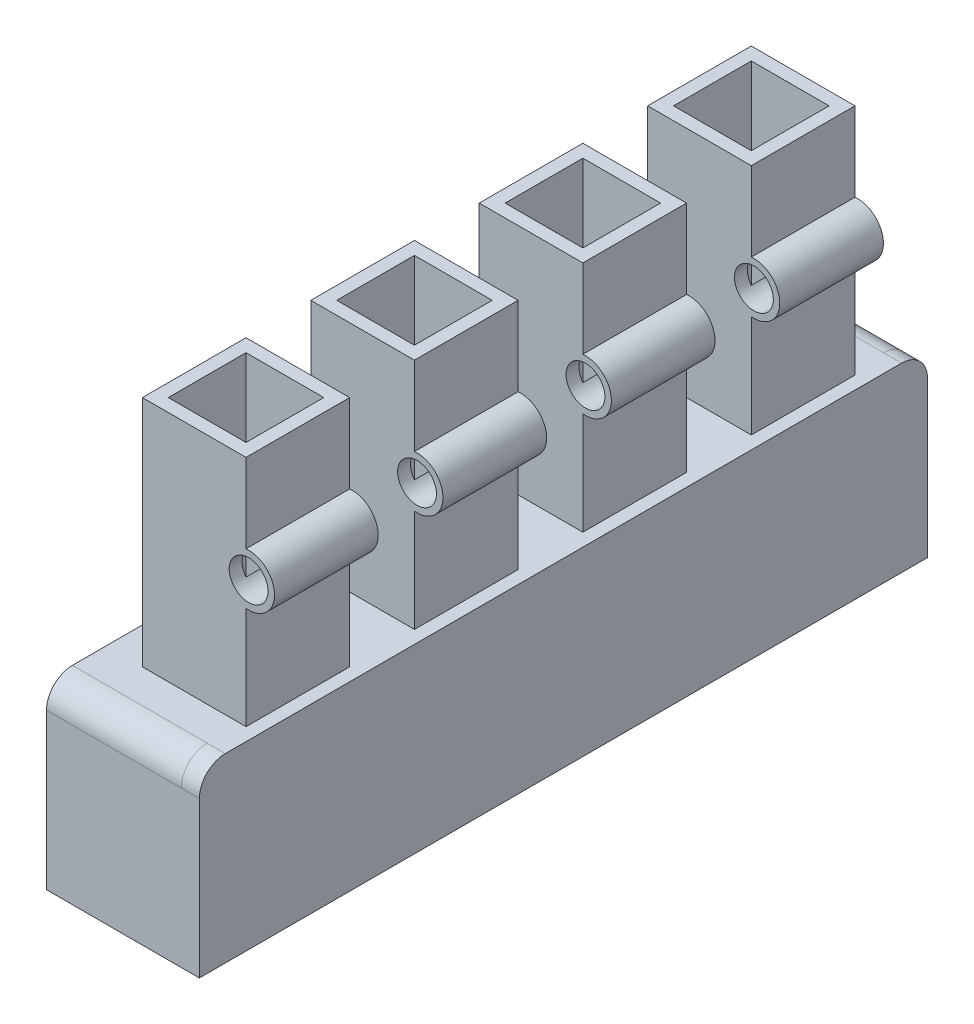
from build123d import *
from build123d.topology import SkipClean

# Parameters (mm, degrees)
BOSS_EXTRUDE1_DEPTH     = 50
BOSS_EXTRUDE2_START     = 9
BOSS_EXTRUDE2_DEPTH     = 9
BOSS_EXTRUDE3_START     = 9
BOSS_EXTRUDE3_DEPTH     = 9
BOSS_EXTRUDE4_DEPTH     = 70
CUT_EXTRUDE2_DEPTH      = 165.74298164110058
CUT_EXTRUDE2_DEPTH_BACK = 165.74298164110058
SKETCH10_W              = 30.000000000000007
SKETCH10_H              = 30
SKETCH10_W_2            = 30.00000000000001
SKETCH10_H_2            = 29.999999999999996
BOSS_EXTRUDE7_DEPTH     = 90
BOSS_EXTRUDE8_DEPTH     = 235
SKETCH12_W              = 24.999999999999993
SKETCH12_H              = 40.90326072663956
SKETCH12_H_2            = 38.73852460954424
SKETCH12_W_2            = 25.000000000000007
SKETCH12_H_3            = 39.91957718910348
CUT_EXTRUDE3_DEPTH      = 235
SKETCH13_R              = 7.499999999999999
CUT_EXTRUDE4_DEPTH      = 235
FILLET1_R               = 10


with BuildPart() as part:
    # Sketch1 → Boss-Extrude1 (new body)
    with BuildSketch(Plane(origin=(0, 0, 0), x_dir=(0, 0, -1), z_dir=(1, 0, 0))):
        with BuildLine():
            Line((-130.5, 0), (130.5, 0))
            ThreePointArc((130.5, 0), (137.57106781186548, -2.9289321881345245), (140.5, -9.999999999999998))
            Line((140.5, -9.999999999999998), (140.5, -69.99999999999999))
            Line((140.5, -69.99999999999999), (122.5, -70))
            ThreePointArc((122.5, -70), (97.5, -45), (72.50000000000001, -70))
            Line((72.50000000000001, -70), (57.5, -70))
            ThreePointArc((57.5, -70), (32.5, -45), (7.5, -70))
            Line((7.5, -70), (-7.5, -70))
            ThreePointArc((-7.5, -70), (-32.5, -45), (-57.5, -70))
            Line((-57.5, -70), (-72.50000000000001, -70))
            ThreePointArc((-72.50000000000001, -70), (-97.5, -45), (-122.5, -70))
            Line((-122.5, -70), (-140.5, -69.99999999999999))
            Line((-140.5, -69.99999999999999), (-140.5, -9.999999999999998))
            ThreePointArc((-140.5, -9.999999999999998), (-137.57106781186548, -2.9289321881345245), (-130.5, 0))
        make_face()
    extrude(amount=BOSS_EXTRUDE1_DEPTH)

    # Sketch2 → Boss-Extrude2 (add)
    with BuildSketch(Plane.ZY.offset(BOSS_EXTRUDE2_START)):
        with BuildLine():
            Line((0, 0), (130.5, 0))
            ThreePointArc((130.5, 0), (137.57106781186548, -2.9289321881345236), (140.5, -9.999999999999998))
            Line((140.5, -9.999999999999998), (140.5, -69.99999999999999))
            Line((140.5, -69.99999999999999), (135.5, -69.99999999999999))
            Line((135.5, -69.99999999999999), (135.5, -15))
            ThreePointArc((135.5, -15), (132.57106781186548, -7.928932188134525), (125.5, -5.000000000000002))
            Line((125.5, -5.000000000000002), (0, -5.000000000000017))
            Line((0, -5.000000000000017), (0, 0))
        make_face()
    extrude(amount=-BOSS_EXTRUDE2_DEPTH)

    # Sketch3 → Boss-Extrude3 (add)
    with BuildSketch(Plane.ZY.offset(BOSS_EXTRUDE3_START)):
        with BuildLine():
            Line((0, 0), (0, -5.000000000000017))
            Line((0, -5.000000000000017), (-125.5, -5.000000000000032))
            ThreePointArc((-125.5, -5.000000000000032), (-132.57106781186548, -7.9289321881345565), (-135.5, -15.000000000000034))
            Line((-135.5, -15.000000000000034), (-135.5, -69.99999999999999))
            Line((-135.5, -69.99999999999999), (-140.5, -69.99999999999999))
            Line((-140.5, -69.99999999999999), (-140.5, -10.00000000000007))
            ThreePointArc((-140.5, -10.00000000000007), (-137.5710678118655, -2.9289321881345742), (-130.50000000000003, 5.2e-15))
            Line((-130.50000000000003, 5.2e-15), (0, 0))
        make_face()
    extrude(amount=-BOSS_EXTRUDE3_DEPTH)

    # Sketch6 → Boss-Extrude4 (add)
    with BuildSketch(Plane(origin=(0, 0, 0), x_dir=(1, 0, 0), z_dir=(0, 1, 0))):
        Polygon((50, -140.5), (50, 140.5), (43, 140.5), (43.000000000000036, -140.5), align=None)
    extrude(amount=-BOSS_EXTRUDE4_DEPTH)

    # Sketch9 → Cut-Extrude2 (cut, two sides: drawn at the far end of the back side and taken through both)
    with BuildSketch(Plane(origin=(0, 0, 0), x_dir=(1, 0, 0), z_dir=(0, 1, 0)).offset(-CUT_EXTRUDE2_DEPTH_BACK)):
        Polygon((40.000000000000675, 47.5), (40.00000000000068, 17.49999999999999), (10.000000000000675, 17.49999999999999), (10.000000000000671, 47.499999999999986), align=None)
        Polygon((39.99999999999999, 112.5), (9.999999999999995, 112.49999999999999), (9.999999999999998, 82.49999999999999), (40, 82.49999999999999), align=None)
        Polygon((40.00000000000135, -17.5), (40.00000000000136, -47.500000000000014), (10.000000000001352, -47.500000000000014), (10.000000000001348, -17.500000000000014), align=None)
        Polygon((40.000000000002025, -82.5), (40.00000000000203, -112.50000000000001), (10.00000000000203, -112.50000000000001), (10.000000000002027, -82.50000000000001), align=None)
    extrude(amount=CUT_EXTRUDE2_DEPTH + CUT_EXTRUDE2_DEPTH_BACK, mode=Mode.SUBTRACT)

    # Sketch10 → Boss-Extrude7 (add)
    # profile 1 of 4: a face of its own
    with BuildSketch(Plane(origin=(0, 0, 0), x_dir=(1, 0, 0), z_dir=(0, 1, 0))):
        Polygon((4.99999999999999, 117.5), (44.99999999999999, 117.5), (45, 77.49999999999999), (4.999999999999995, 77.49999999999999), align=None)
        with Locations((24.999999999999996, 97.49999999999999)):
            Rectangle(SKETCH10_W, SKETCH10_H, mode=Mode.SUBTRACT)
    # profile 2 of 4: a face of its own
    with BuildSketch(Plane(origin=(0, 0, 0), x_dir=(1, 0, 0), z_dir=(0, 1, 0))):
        Polygon((5.000000000000667, 52.49999999999999), (5.0000000000006715, 12.499999999999984), (45.000000000000675, 12.499999999999984), (45.00000000000067, 52.49999999999999), align=None)
        with Locations((25.000000000000675, 32.499999999999986)):
            Rectangle(SKETCH10_W_2, SKETCH10_H_2, mode=Mode.SUBTRACT)
    # profile 3 of 4: a face of its own
    with BuildSketch(Plane(origin=(0, 0, 0), x_dir=(1, 0, 0), z_dir=(0, 1, 0))):
        Polygon((5.000000000001345, -12.50000000000001), (5.000000000001349, -52.50000000000002), (45.00000000000135, -52.50000000000002), (45.00000000000134, -12.50000000000001), align=None)
        with Locations((25.000000000001354, -32.500000000000014)):
            Rectangle(SKETCH10_W, SKETCH10_H, mode=Mode.SUBTRACT)
    # profile 4 of 4: a face of its own
    with BuildSketch(Plane(origin=(0, 0, 0), x_dir=(1, 0, 0), z_dir=(0, 1, 0))):
        Polygon((5.0000000000020215, -77.50000000000001), (5.000000000002025, -117.50000000000001), (45.00000000000203, -117.50000000000001), (45.000000000002025, -77.50000000000001), align=None)
        with Locations((25.00000000000203, -97.50000000000001)):
            Rectangle(SKETCH10_W, SKETCH10_H, mode=Mode.SUBTRACT)
    extrude(amount=BOSS_EXTRUDE7_DEPTH)

    # Sketch11 → Boss-Extrude8 (add)
    with BuildSketch(Plane.XY.offset(117.50000000000001)):
        with BuildLine():
            Line((45.00000000000203, 59.449874371066194), (45.00000000000203, 56.93303437365923))
            ThreePointArc((45.00000000000203, 56.93303437365923), (53.50000000000204, 49.499999999999986), (45.00000000000203, 42.06696562634074))
            Line((45.00000000000203, 42.06696562634074), (45.00000000000203, 39.55012562893379))
            ThreePointArc((45.00000000000203, 39.5501256289338), (56.000000000002046, 49.5), (45.00000000000203, 59.4498743710662))
        make_face()
    extrude(amount=-BOSS_EXTRUDE8_DEPTH)

    # Sketch12 → Cut-Extrude3 (cut)
    with BuildSketch(Plane(origin=(0, 0, 0), x_dir=(0, 0, -1), z_dir=(1, 0, 0))):
        with Locations((-65.00000000000001, 54.273306822213314)):
            Rectangle(SKETCH12_W, SKETCH12_H)
        with Locations((-1.421e-14, 51.301254636370814)):
            Rectangle(SKETCH12_W, SKETCH12_H_2)
        with Locations((65, 47.16757060791335)):
            Rectangle(SKETCH12_W_2, SKETCH12_H_3)
    extrude(amount=CUT_EXTRUDE3_DEPTH, mode=Mode.SUBTRACT)

    # Sketch13 → Cut-Extrude4 (cut)
    with SkipClean():  # the faces are left unmerged after this step: merging them gives an invalid solid
        with BuildSketch(Plane.XY.offset(117.50000000000001)):
            with Locations((46.000000000002046, 49.499999999999986)):
                Circle(SKETCH13_R)
        extrude(amount=-CUT_EXTRUDE4_DEPTH, mode=Mode.SUBTRACT)

    # Fillet1
    fillet1_edges = [part.edges().sort_by_distance(p)[0] for p in [
        (46.500000000000014, 0, 140.5),
        (46.5, 0, -140.5),
    ]]
    fillet(fillet1_edges, radius=FILLET1_R)


solid = part.part
